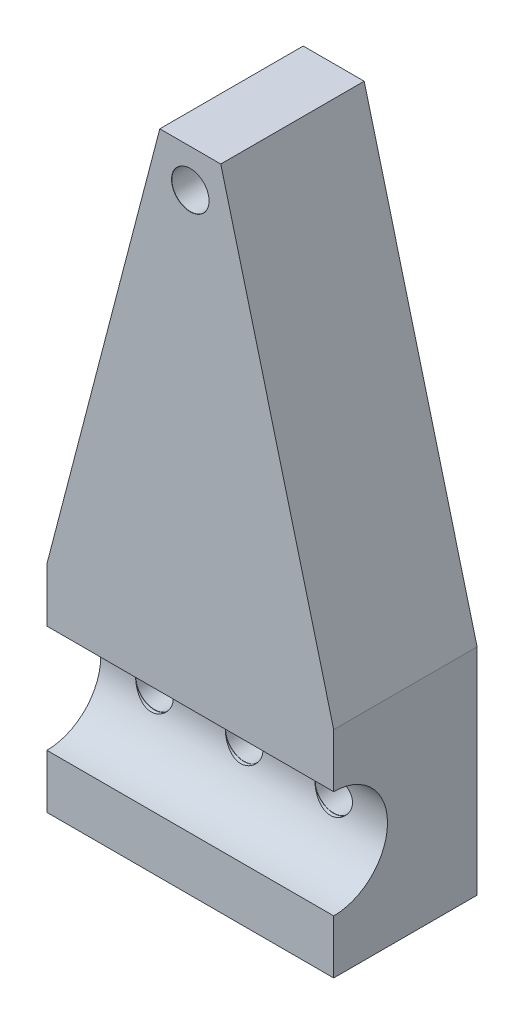
from build123d import *

# Parameters (mm, degrees)
SKETCH1_W                                = 50.8
SKETCH1_H                                = 38.1
BOSS_EXTRUDE1_DEPTH                      = 25.4
CUT_SWEEP1_PROFILE_R                     = 9.525
M6_CLEARANCE_HOLE1_D                     = 6.6
M6_CLEARANCE_HOLE1_CSINK_D               = 6.65
M6_CLEARANCE_HOLE1_CSINK_ANGLE           = 90
M6_CLEARANCE_HOLE1_ON_FACE_2_D           = 6.6
M6_CLEARANCE_HOLE1_ON_FACE_2_CSINK_D     = 6.65
M6_CLEARANCE_HOLE1_ON_FACE_2_CSINK_ANGLE = 90


with BuildPart() as part:
    # Sketch1 → Boss-Extrude1 (new body)
    with BuildSketch(Plane.XY):
        Polygon((5.399653784, 95.801105715), (25.4, 19.05), (-25.4, 19.05), (-5.399653784, 95.801105715), align=None)
        Rectangle(SKETCH1_W, SKETCH1_H)
    extrude(amount=BOSS_EXTRUDE1_DEPTH)

    # Cut-Sweep1: sweep along a path in Sketch2
    with BuildLine(Plane.XY.offset(25.4)) as cut_sweep1_path:
        Line((-25.4, 0), (25.4, 0))
    # Cut-Sweep1 profile (on start of the path) → Cut-Sweep1 (sweep, cut)
    with BuildSketch(Plane(origin=(-25.4, 0, 25.4), x_dir=(0, 1, 0), z_dir=(1, 0, 0))):
        Circle(CUT_SWEEP1_PROFILE_R)
    sweep(path=cut_sweep1_path.line, mode=Mode.SUBTRACT)

    # M6 Clearance Hole1 (through all)
    with Locations(Plane(origin=(0, 0, 15.875), x_dir=(0, 1, 0), z_dir=(0, 0, 1))):
        with Locations((0, 0), (0, 15.875), (0, -15.875)):
            CounterSinkHole(M6_CLEARANCE_HOLE1_D / 2, M6_CLEARANCE_HOLE1_CSINK_D / 2, counter_sink_angle=M6_CLEARANCE_HOLE1_CSINK_ANGLE)

    # M6 Clearance Hole1 on face 2 (through all)
    with Locations(Plane(origin=(0, 89.092444953, 25.4), x_dir=(1, 0, 0), z_dir=(0, 0, 1))):
        with Locations((0, 0)):
            CounterSinkHole(M6_CLEARANCE_HOLE1_ON_FACE_2_D / 2, M6_CLEARANCE_HOLE1_ON_FACE_2_CSINK_D / 2, counter_sink_angle=M6_CLEARANCE_HOLE1_ON_FACE_2_CSINK_ANGLE)


solid = part.part
